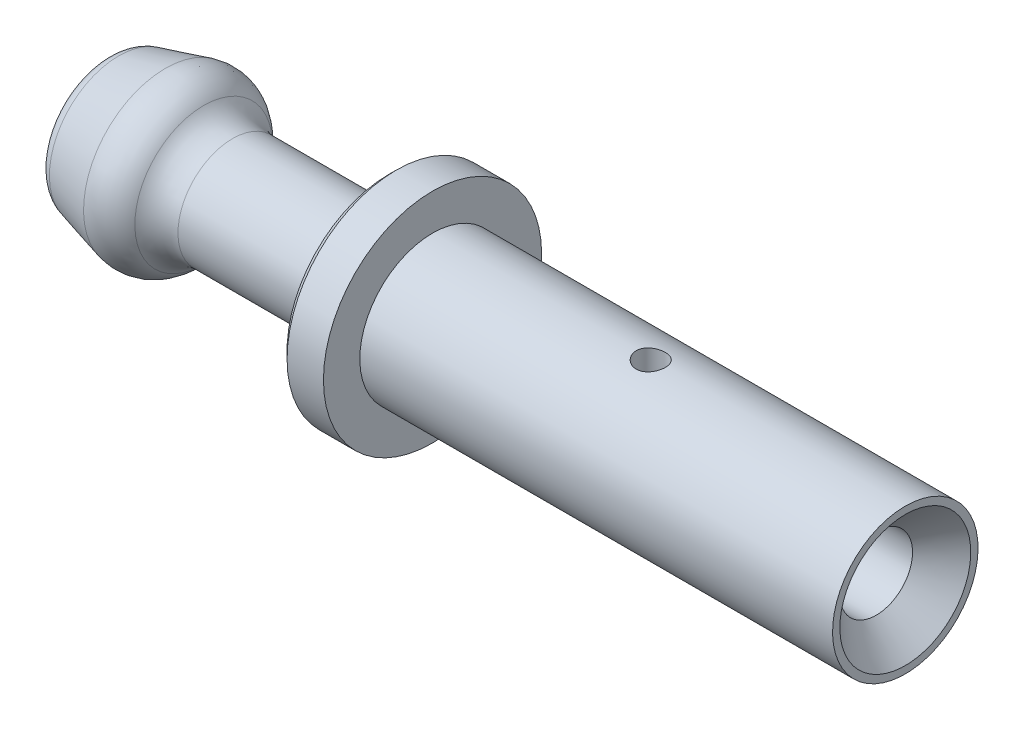
from build123d import *

# Parameters (mm, degrees)
SKETCH2_R          = 0.4
CUT_EXTRUDE1_DEPTH = 4


with BuildPart() as part:
    # Sketch1 → Revolve1 (revolve)
    with BuildSketch(Plane.XY):
        with BuildLine():
            Line((0, 1.8), (-0.8, 1))
            Line((-0.8, 1), (-7.711324865, 1))
            Line((-7.711324865, 1), (-8, 0.5))
            Line((-8, 0.5), (-21.5, 0.5))
            Line((-21.5, 0.5), (-22, 1))
            Line((-22, 1), (-22, 1.423349476))
            ThreePointArc((-22, 1.423349476), (-21.89667667, 1.72773019), (-21.629409523, 1.906312389))
            Line((-21.629409523, 1.906312389), (-20.346749895, 2.25))
            ThreePointArc((-20.346749895, 2.25), (-19.766015063, 2.23084248), (-19.293965425, 1.892037087))
            ThreePointArc((-19.293965425, 1.892037087), (-18.942739815, 1.603349869), (-18.5, 1.5))
            Line((-18.5, 1.5), (-15, 1.5))
            ThreePointArc((-15, 1.5), (-14.434314575, 1.734314575), (-14.2, 2.3))
            Line((-14.2, 2.3), (-14.2, 2.8))
            Line((-14.2, 2.8), (-14, 3))
            Line((-14, 3), (-13, 3))
            Line((-13, 3), (-13, 2))
            Line((-13, 2), (0, 2))
            Line((0, 2), (0, 1.8))
        make_face()
    revolve(axis=Axis((0, 0, 0), (-1, 0, 0)))

    # Sketch2 → Cut-Extrude1 (cut, through all)
    with BuildSketch(Plane(origin=(0, 0, 0), x_dir=(1, 0, 0), z_dir=(0, 1, 0))):
        with Locations(Location((-7, 0, 0), (0, 0, 180))):  # turned: the seam where the file's is
            Circle(SKETCH2_R)
    extrude(amount=CUT_EXTRUDE1_DEPTH, mode=Mode.SUBTRACT)


solid = part.part
